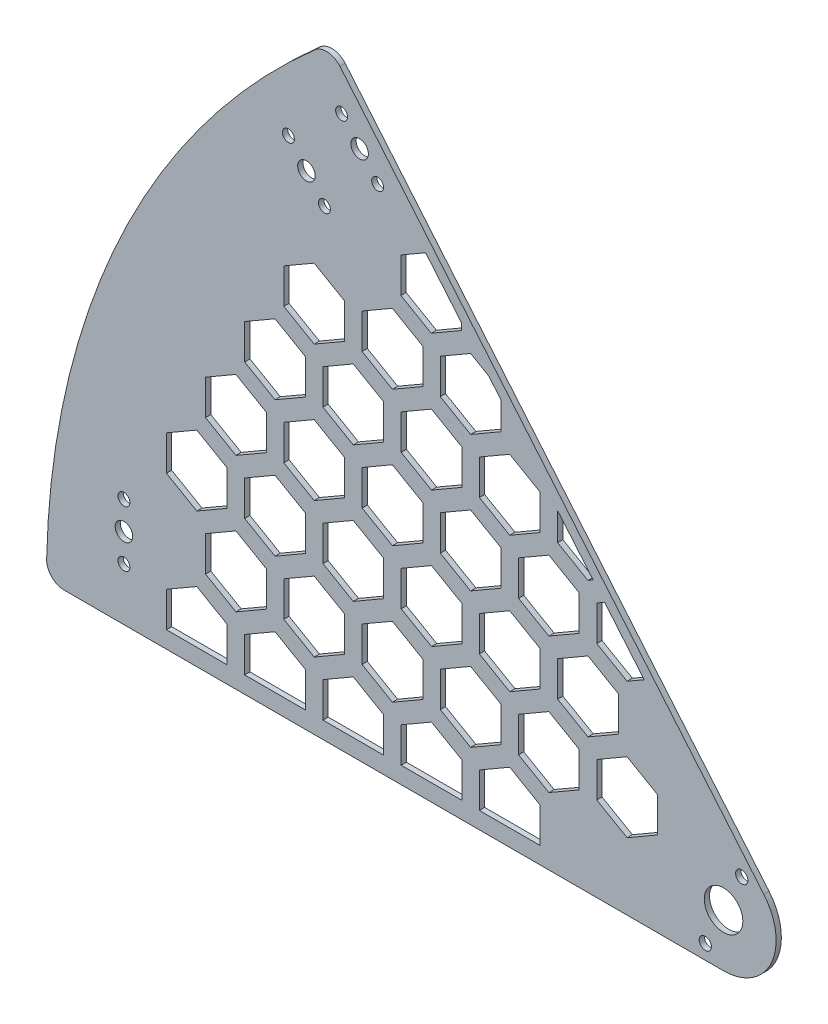
from build123d import *

# Parameters (mm, degrees)
SKETCH1_R           = 11
SKETCH1_R_2         = 5
SKETCH1_R_3         = 3.4
BOSS_EXTRUDE1_DEPTH = 3
CUT_EXTRUDE1_DEPTH  = 3
SKETCH3_R           = 3.5
CUT_EXTRUDE2_DEPTH  = 4


with BuildPart() as part:
    # Sketch1 → Boss-Extrude1 (new body)
    with BuildSketch(Plane.XY):
        with BuildLine():
            Line((22.981333294, 19.283628291), (-218.858843748, 307.497528114))
            ThreePointArc((-218.858843748, 307.497528114), (-225.760822062, 311.040846988), (-233.119339435, 308.582262976))
            ThreePointArc((-233.119339435, 308.582262976), (-344.124305549, 160.467799035), (-386.233950765, -19.773080652))
            ThreePointArc((-386.233950765, -19.773080652), (-383.387371592, -26.990379336), (-376.236525716, -30))
            Line((-376.236525716, -30), (0, -30))
            ThreePointArc((0, -30), (27.189233611, -12.678547852), (22.981333294, 19.283628291))
        make_face()
        Circle(SKETCH1_R, mode=Mode.SUBTRACT)
        with Locations((-207.657689748, 272.368379017)):
            Circle(SKETCH1_R_2, mode=Mode.SUBTRACT)
        with Locations((-237.996681226, 246.300283649)):
            Circle(SKETCH1_R_2, mode=Mode.SUBTRACT)
        with Locations((-342.126073253, 15.999999999)):
            Circle(SKETCH1_R_2, mode=Mode.SUBTRACT)
        with Locations((-248.28128298, 258.556994739)):
            Circle(SKETCH1_R_3, mode=Mode.SUBTRACT)
        with Locations((-227.71207947, 234.043572559)):
            Circle(SKETCH1_R_3, mode=Mode.SUBTRACT)
        with Locations((-197.373087993, 260.111667927)):
            Circle(SKETCH1_R_3, mode=Mode.SUBTRACT)
        with Locations((-217.942291503, 284.625090107)):
            Circle(SKETCH1_R_3, mode=Mode.SUBTRACT)
        with Locations((-342.126073253, -1e-09)):
            Circle(SKETCH1_R_3, mode=Mode.SUBTRACT)
        with Locations((-342.126073253, 31.999999999)):
            Circle(SKETCH1_R_3, mode=Mode.SUBTRACT)
    extrude(amount=BOSS_EXTRUDE1_DEPTH)

    # Sketch2 → Cut-Extrude1 (cut)
    with BuildSketch(Plane.XY.offset(3)):
        Polygon((-45.259370615, 91.22851897), (-67.869688112, 118.174446076), (-72.342138965, 115.592275372), (-72.342138965, 95.592275373), (-55.021630889, 85.592275373), align=None)
        Polygon((-260.90620357, 18.271767297), (-260.90620357, 38.271767297), (-278.226711646, 48.271767297), (-295.547219722, 38.271767297), (-295.547219722, 18.271767297), (-278.226711646, 8.271767297), align=None)
        Polygon((-283.226711646, -20.388486741), (-283.226711646, -0.388486741), (-300.547219722, 9.611513259), (-317.867727798, -0.388486741), (-317.867727798, -20.388486741), align=None)
        Polygon((-104.662647041, -20.388486741), (-139.303663192, -20.388486741), (-139.303663192, -0.388486741), (-121.983155116, 9.611513259), (-104.662647041, -0.388486741), align=None)
        Polygon((-238.585695495, 56.932021335), (-238.585695495, 76.932021335), (-255.90620357, 86.932021335), (-273.226711646, 76.932021335), (-273.226711646, 56.932021335), (-255.90620357, 46.932021335), align=None)
        Polygon((-216.265187419, 95.592275372), (-216.265187419, 115.592275372), (-233.585695495, 125.592275372), (-250.90620357, 115.592275372), (-250.90620357, 95.592275373), (-233.585695495, 85.592275372), align=None)
        Polygon((-193.944679343, 134.25252941), (-193.944679343, 154.25252941), (-211.265187419, 164.25252941), (-228.585695495, 154.25252941), (-228.585695495, 134.25252941), (-211.265187419, 124.25252941), align=None)
        Polygon((-171.624171268, 172.912783448), (-171.624171268, 192.912783448), (-188.944679343, 202.912783448), (-206.265187419, 192.912783448), (-206.265187419, 172.912783448), (-188.944679343, 162.912783448), align=None)
        Polygon((-216.265187419, 18.271767297), (-216.265187419, 38.271767297), (-233.585695495, 48.271767297), (-250.906203571, 38.271767297), (-250.90620357, 18.271767297), (-233.585695495, 8.271767297), align=None)
        Polygon((-193.944679343, 56.932021335), (-193.944679343, 76.932021335), (-211.265187419, 86.932021335), (-228.585695495, 76.932021335), (-228.585695495, 56.932021335), (-211.265187204, 46.932021211), align=None)
        Polygon((-171.624171268, 95.592275372), (-171.624171268, 115.592275372), (-188.944679343, 125.592275372), (-206.265187419, 115.592275372), (-206.265187419, 95.592275373), (-188.944679343, 85.592275372), align=None)
        Polygon((-149.303663192, 134.25252941), (-149.303663192, 154.25252941), (-166.624171268, 164.25252941), (-183.944679343, 154.25252941), (-183.944679343, 134.25252941), (-166.624171268, 124.25252941), align=None)
        Polygon((-126.983155116, 172.912783448), (-126.983155116, 188.62313275), (-133.964970701, 196.943736555), (-144.303663192, 202.912783448), (-161.624171268, 192.912783448), (-161.624171268, 172.912783448), (-144.303663192, 162.912783448), align=None)
        Polygon((-171.624171268, 18.271767297), (-171.624171268, 38.271767297), (-188.944679343, 48.271767297), (-206.265187419, 38.271767297), (-206.265187419, 18.271767297), (-188.944679236, 8.271767111), align=None)
        Polygon((-149.303663192, 56.932021335), (-149.303663192, 76.932021335), (-166.624171268, 86.932021335), (-183.944679343, 76.932021335), (-183.944679343, 56.932021335), (-166.624171268, 46.932021335), align=None)
        Polygon((-126.983155116, 95.592275372), (-126.983155116, 115.592275372), (-144.303663192, 125.592275372), (-161.624171268, 115.592275372), (-161.624171268, 95.592275373), (-144.303663192, 85.592275372), align=None)
        Polygon((-104.662647041, 134.25252941), (-104.662647041, 154.25252941), (-121.983155116, 164.25252941), (-139.303663192, 154.25252941), (-139.303663192, 134.25252941), (-121.983155116, 124.25252941), align=None)
        Polygon((-126.983155116, 18.271767297), (-126.983155116, 38.271767297), (-144.303663192, 48.271767297), (-161.624171268, 38.271767297), (-161.624171268, 18.271767297), (-144.303663192, 8.271767297), align=None)
        Polygon((-104.662647041, 56.932021335), (-104.662647041, 76.932021335), (-121.983155116, 86.932021335), (-139.303663192, 76.932021335), (-139.303663192, 56.932021335), (-121.983155116, 46.932021335), align=None)
        Polygon((-82.342138965, 95.592275372), (-82.342138965, 115.592275372), (-99.662647041, 125.592275372), (-116.983155116, 115.592275372), (-116.983155116, 95.592275373), (-99.662647041, 85.592275372), align=None)
        Polygon((-94.662647041, 150.105051136), (-94.662647041, 134.25252941), (-77.342138965, 124.25252941), (-74.396724559, 125.953065211), align=None)
        Polygon((-82.342138965, 18.271767297), (-82.342138965, 38.271767297), (-99.662647041, 48.271767297), (-116.983155116, 38.271767297), (-116.983155116, 18.271767297), (-99.662647041, 8.271767297), align=None)
        Polygon((-60.021630889, 56.932021335), (-60.021630889, 76.932021335), (-77.342138965, 86.932021335), (-94.662647041, 76.932021335), (-94.662647041, 56.932021335), (-77.342138965, 46.932021335), align=None)
        Polygon((-238.585695495, -20.388486741), (-238.585695495, -0.388486741), (-255.906203571, 9.611513259), (-273.226711646, -0.388486741), (-273.226711646, -20.388486741), align=None)
        Polygon((-193.944679343, -20.388486741), (-193.944679343, -0.388486741), (-211.265187419, 9.611513259), (-228.585695495, -0.388486741), (-228.585695495, -20.388486741), align=None)
        Polygon((-149.303663192, -20.388486741), (-149.303663192, -0.388486741), (-166.624171268, 9.611513259), (-183.944679343, -0.388486741), (-183.944679343, -20.388486741), align=None)
        Polygon((-283.226711646, 56.932021335), (-283.226711646, 76.932021335), (-300.547219722, 86.932021335), (-317.867727798, 76.932021335), (-317.867727798, 56.932021335), (-300.547219722, 46.932021335), align=None)
        Polygon((-260.906203571, 95.592275372), (-260.906203571, 115.592275372), (-278.226711646, 125.592275372), (-295.547219722, 115.592275372), (-295.547219722, 95.592275373), (-278.226711646, 85.592275372), align=None)
        Polygon((-238.585695495, 134.25252941), (-238.585695495, 154.25252941), (-255.906203571, 164.25252941), (-273.226711646, 154.25252941), (-273.226711646, 134.25252941), (-255.906203571, 124.25252941), align=None)
        Polygon((-216.265187419, 172.912783448), (-216.265187419, 192.912783448), (-233.585695495, 202.912783448), (-250.90620357, 192.912783448), (-250.90620357, 172.912783448), (-233.585695495, 162.912783448), align=None)
        Polygon((-149.483155116, 211.676667197), (-149.483155116, 215.437588583), (-169.967581948, 239.849977852), (-184.124171268, 231.676667197), (-184.124171268, 211.676667197), (-166.803663192, 201.676667197), align=None)
        Polygon((-37.701122814, 18.271767297), (-37.701122814, 38.271767297), (-55.021630889, 48.271767297), (-72.342138965, 38.271767297), (-72.342138965, 18.271767297), (-55.021630889, 8.271767297), align=None)
    extrude(amount=-CUT_EXTRUDE1_DEPTH, mode=Mode.SUBTRACT)

    # Sketch3 → Cut-Extrude2 (cut, through all)
    with BuildSketch(Plane(origin=(0, 0, 0), x_dir=(-1, 0, 0), z_dir=(0, 0, -1))):
        with Locations((-10.404821813, 21.627290238)):
            Circle(SKETCH3_R)
        with Locations((10.404821813, -21.627290238)):
            Circle(SKETCH3_R)
    extrude(amount=-CUT_EXTRUDE2_DEPTH, mode=Mode.SUBTRACT)


solid = part.part
